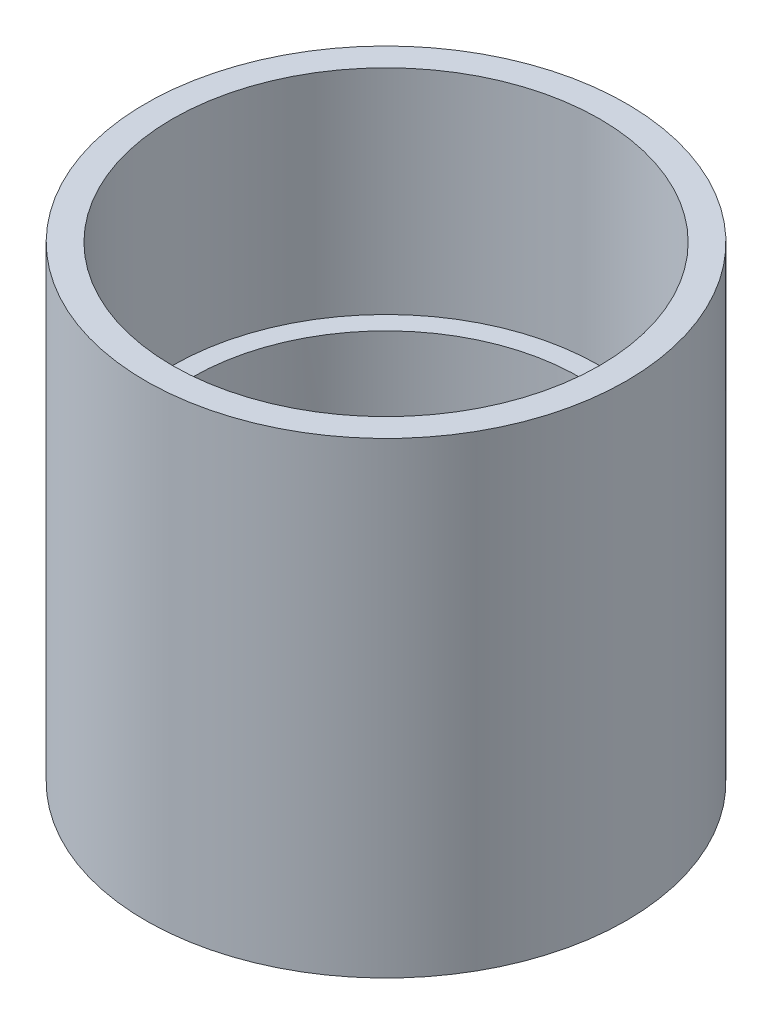
from build123d import *

# Parameters (mm, degrees)
SKETCH2_R          = 16
CUT_EXTRUDE1_DEPTH = 16


with BuildPart() as part:
    # Sketch1 → Revolve1 (revolve)
    with BuildSketch(Plane.XY):
        Polygon((16, -17.5), (16, -4.5), (14.5, -4.5), (14.5, 17.5), (18, 17.5), (18, -17.5), align=None)
    revolve(axis=Axis((0, -1459.892614339, 0), (0, 1, 0)))

    # Sketch2 → Cut-Extrude1 (cut)
    with BuildSketch(Plane(origin=(0, 17.5, 0), x_dir=(1, 0, 0), z_dir=(0, 1, 0))):
        Circle(SKETCH2_R)
    extrude(amount=-CUT_EXTRUDE1_DEPTH, mode=Mode.SUBTRACT)


solid = part.part
